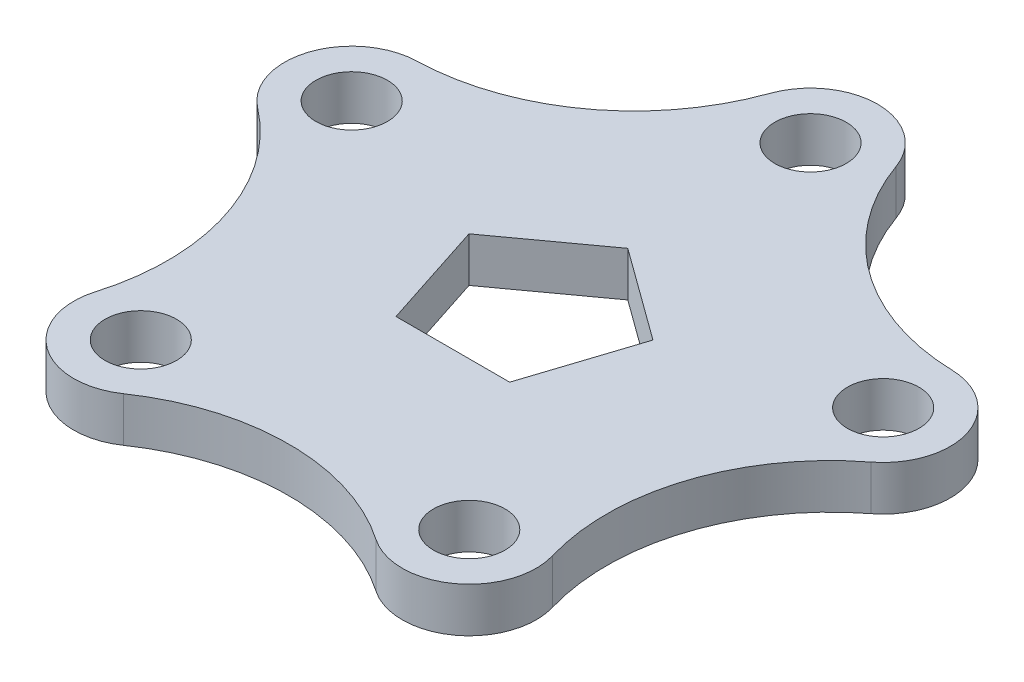
from build123d import *

# Parameters (mm, degrees)
SKETCH1_R           = 8
BOSS_EXTRUDE2_DEPTH = 5


with BuildPart() as part:
    # Sketch1 → Boss-Extrude2 (new body, symmetric)
    with BuildSketch(Plane(origin=(0, 0, 0), x_dir=(1, 0, 0), z_dir=(0, 1, 0))):
        with BuildLine():
            ThreePointArc((14.132148934, 67.528157367), (0, 77.5), (-14.132148934, 67.528157367))
            ThreePointArc((-14.132148934, 67.528157367), (-31.850049433, 43.837832205), (-59.85601991, 34.307820558))
            ThreePointArc((-59.85601991, 34.307820558), (-73.706880013, 23.948817064), (-68.590168285, 7.426875892))
            ThreePointArc((-68.590168285, 7.426875892), (-51.534462525, -16.744561909), (-51.125203669, -46.324758182))
            ThreePointArc((-51.125203669, -46.324758182), (-45.553357053, -62.698817064), (-28.25890636, -62.938095635))
            ThreePointArc((-28.25890636, -62.938095635), (0, -54.186540592), (28.25890636, -62.938095635))
            ThreePointArc((28.25890636, -62.938095635), (45.553357053, -62.698817064), (51.125203669, -46.324758182))
            ThreePointArc((51.125203669, -46.324758182), (51.534462525, -16.744561909), (68.590168285, 7.426875892))
            ThreePointArc((68.590168285, 7.426875892), (73.706880013, 23.948817064), (59.85601991, 34.307820558))
            ThreePointArc((59.85601991, 34.307820558), (31.850049433, 43.837832205), (14.132148934, 67.528157367))
        make_face()
        with Locations((0, 62.5)):
            Circle(SKETCH1_R, mode=Mode.SUBTRACT)
        with Locations((59.441032268, 19.313562148)):
            Circle(SKETCH1_R, mode=Mode.SUBTRACT)
        with Locations((36.736578268, -50.563562148)):
            Circle(SKETCH1_R, mode=Mode.SUBTRACT)
        with Locations((-36.736578268, -50.563562148)):
            Circle(SKETCH1_R, mode=Mode.SUBTRACT)
        with Locations((-59.441032268, 19.313562148)):
            Circle(SKETCH1_R, mode=Mode.SUBTRACT)
        Polygon((0, 21.631189606), (-20.57248383, 6.684405197), (-12.71449424, -17.5), (12.71449424, -17.5), (20.57248383, 6.684405197), align=None, mode=Mode.SUBTRACT)
    extrude(amount=BOSS_EXTRUDE2_DEPTH, both=True)


solid = part.part
